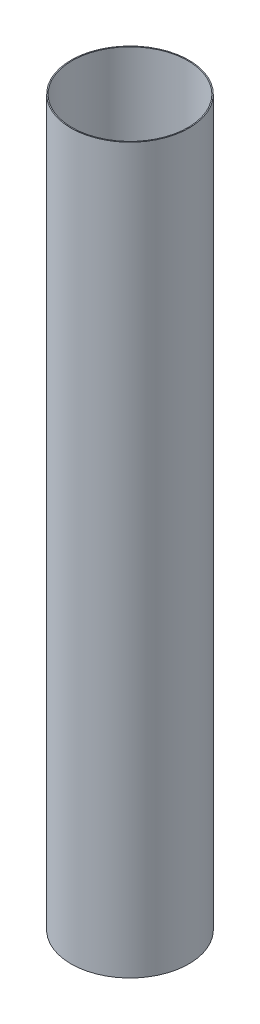
from build123d import *

# Parameters (mm, degrees)
SKETCH1_R           = 38.1
SKETCH1_R_2         = 37.465
BOSS_EXTRUDE1_DEPTH = 467.868


with BuildPart() as part:
    # Sketch1 → Boss-Extrude1 (new body)
    with BuildSketch(Plane(origin=(0, 0, 0), x_dir=(1, 0, 0), z_dir=(0, 1, 0))):
        Circle(SKETCH1_R)
        Circle(SKETCH1_R_2, mode=Mode.SUBTRACT)
    extrude(amount=BOSS_EXTRUDE1_DEPTH)


solid = part.part
